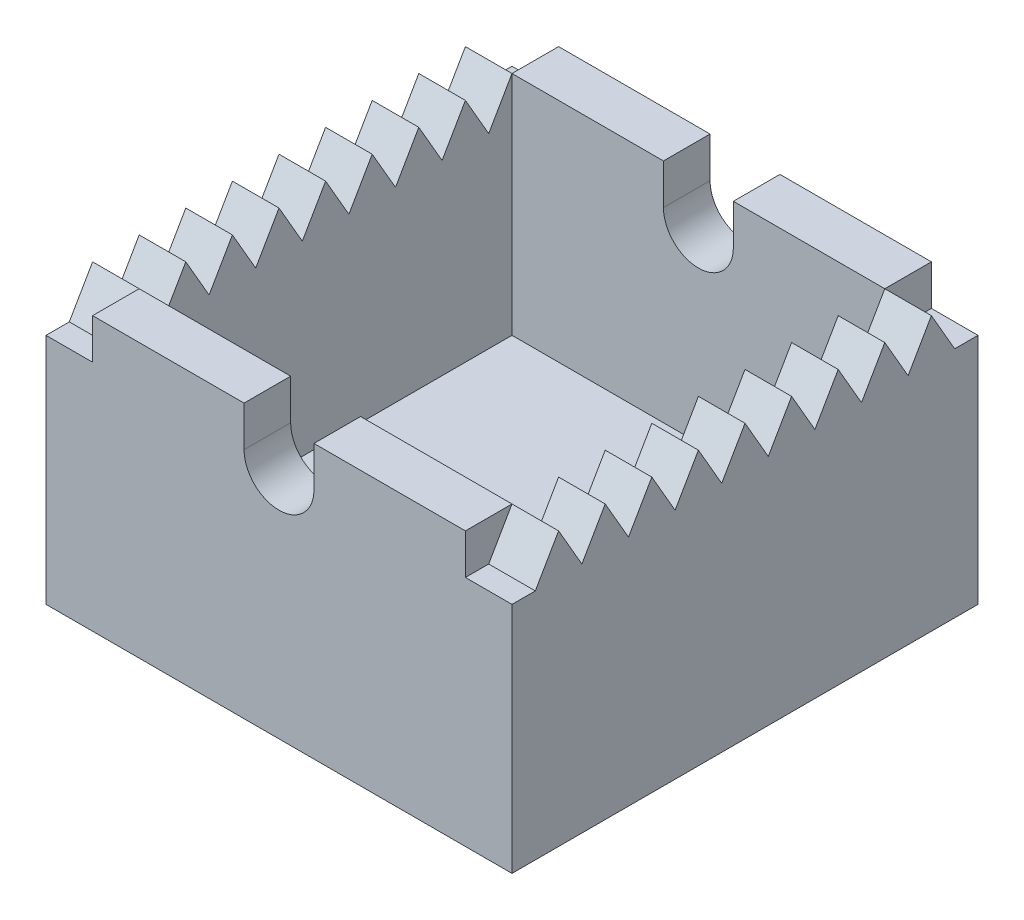
from build123d import *

# Parameters (mm, degrees)
SKETCH1_W           = 100
SKETCH1_H           = 100
BOSS_EXTRUDE1_DEPTH = 25
SKETCH4_W           = 80
SKETCH4_H           = 80
CUT_EXTRUDE2_DEPTH  = 40
SKETCH5_R           = 7.5
CUT_EXTRUDE3_DEPTH  = 100
BOSS_EXTRUDE4_DEPTH = 10
BOSS_EXTRUDE5_DEPTH = 10
BOSS_EXTRUDE6_START = -90
SKETCH9_W           = 32.5
SKETCH9_H           = 8.660254038
BOSS_EXTRUDE6_DEPTH = 10
SKETCH11_W          = 32.5
SKETCH11_H          = 8.660254038
BOSS_EXTRUDE8_DEPTH = 10


with BuildPart() as part:
    # Sketch1 → Boss-Extrude1 (new body, symmetric)
    with BuildSketch(Plane(origin=(0, 0, 0), x_dir=(1, 0, 0), z_dir=(0, 1, 0))):
        Rectangle(SKETCH1_W, SKETCH1_H)
    extrude(amount=BOSS_EXTRUDE1_DEPTH, both=True)

    # Sketch4 → Cut-Extrude2 (cut)
    with BuildSketch(Plane(origin=(0, 25, 0), x_dir=(1, 0, 0), z_dir=(0, 1, 0))):
        Rectangle(SKETCH4_W, SKETCH4_H)
    extrude(amount=-CUT_EXTRUDE2_DEPTH, mode=Mode.SUBTRACT)

    # Sketch5 → Cut-Extrude3 (cut)
    with BuildSketch(Plane.XY.offset(50)):
        with Locations((0, 25)):
            Circle(SKETCH5_R)
    extrude(amount=-CUT_EXTRUDE3_DEPTH, mode=Mode.SUBTRACT)

    # Sketch7 → Boss-Extrude4 (add)
    with BuildSketch(Plane.ZY.offset(50)):
        Polygon((40, 33.660254038), (35, 25), (45, 25), align=None)
        Polygon((30, 33.660254038), (25, 25), (35, 25), align=None)
        Polygon((20, 33.660254038), (15, 25), (25, 25), align=None)
        Polygon((10, 33.660254038), (5, 25), (15, 25), align=None)
        Polygon((0, 33.660254038), (-5, 25), (5, 25), align=None)
        Polygon((-10, 33.660254038), (-15, 25), (-5, 25), align=None)
        Polygon((-20, 33.660254038), (-25, 25), (-15, 25), align=None)
        Polygon((-30, 33.660254038), (-35, 25), (-25, 25), align=None)
        Polygon((-40, 33.660254038), (-45, 25), (-35, 25), align=None)
    extrude(amount=-BOSS_EXTRUDE4_DEPTH)

    # Sketch8 → Boss-Extrude5 (add)
    with BuildSketch(Plane(origin=(50, 0, 0), x_dir=(0, 0, -1), z_dir=(1, 0, 0))):
        Polygon((40, 33.660254038), (35, 25), (45, 25), align=None)
        Polygon((30, 33.660254038), (25, 25), (35, 25), align=None)
        Polygon((20, 33.660254038), (15, 25), (25, 25), align=None)
        Polygon((10, 33.660254038), (5, 25), (15, 25), align=None)
        Polygon((0, 33.660254038), (-5, 25), (5, 25), align=None)
        Polygon((-10, 33.660254038), (-15, 25), (-5, 25), align=None)
        Polygon((-20, 33.660254038), (-25, 25), (-15, 25), align=None)
        Polygon((-30, 33.660254038), (-35, 25), (-25, 25), align=None)
        Polygon((-40, 33.660254038), (-45, 25), (-35, 25), align=None)
    extrude(amount=-BOSS_EXTRUDE5_DEPTH)

    # Sketch9 → Boss-Extrude6 (add)
    with BuildSketch(Plane.XY.offset(50).offset(BOSS_EXTRUDE6_START)):
        with Locations((-23.75, 29.330127019)):
            Rectangle(SKETCH9_W, SKETCH9_H)
        with Locations((23.75, 29.330127019)):
            Rectangle(SKETCH9_W, SKETCH9_H)
    extrude(amount=-BOSS_EXTRUDE6_DEPTH)

    # Sketch11 → Boss-Extrude8 (add)
    with BuildSketch(Plane.XY.offset(50)):
        with Locations((-23.75, 29.330127019)):
            Rectangle(SKETCH11_W, SKETCH11_H)
        with Locations((23.75, 29.330127019)):
            Rectangle(SKETCH11_W, SKETCH11_H)
    extrude(amount=-BOSS_EXTRUDE8_DEPTH)


solid = part.part
